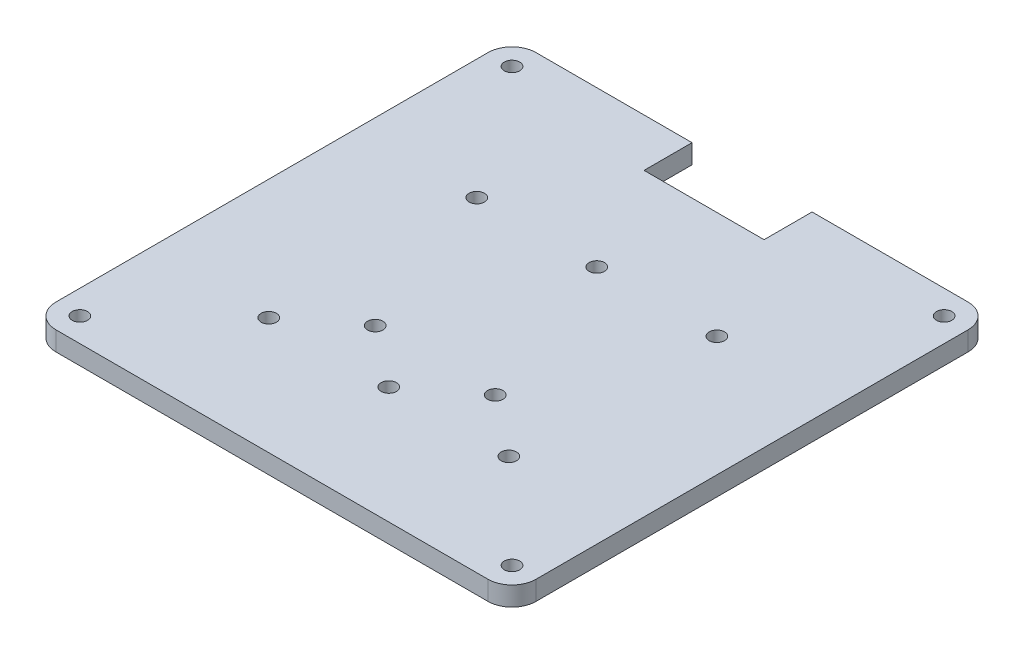
from build123d import *

# Parameters (mm, degrees)
SKETCH1_R           = 1.6
BOSS_EXTRUDE1_DEPTH = 4
FILLET1_R           = 5


with BuildPart() as part:
    # Sketch1 → Boss-Extrude1 (new body)
    with BuildSketch(Plane(origin=(0, 0, 0), x_dir=(1, 0, 0), z_dir=(0, 1, 0))):
        Polygon((-50, -50), (50, -50), (50, 50), (12.5, 50), (12.5, 40), (-12.5, 40), (-12.5, 50), (-50, 50), align=None)
        with Locations((-45, -45)):
            Circle(SKETCH1_R, mode=Mode.SUBTRACT)
        with Locations((-25, -25.66)):
            Circle(SKETCH1_R, mode=Mode.SUBTRACT)
        with Locations((-12.5, -16)):
            Circle(SKETCH1_R, mode=Mode.SUBTRACT)
        with Locations((0, -25.66)):
            Circle(SKETCH1_R, mode=Mode.SUBTRACT)
        with Locations((45, -45)):
            Circle(SKETCH1_R, mode=Mode.SUBTRACT)
        with Locations((25, -25.66)):
            Circle(SKETCH1_R, mode=Mode.SUBTRACT)
        with Locations((12.5, -16)):
            Circle(SKETCH1_R, mode=Mode.SUBTRACT)
        with Locations((-25, 17.66)):
            Circle(SKETCH1_R, mode=Mode.SUBTRACT)
        with Locations((-45, 45)):
            Circle(SKETCH1_R, mode=Mode.SUBTRACT)
        with Locations((0, 17.66)):
            Circle(SKETCH1_R, mode=Mode.SUBTRACT)
        with Locations((25, 17.66)):
            Circle(SKETCH1_R, mode=Mode.SUBTRACT)
        with Locations((45, 45)):
            Circle(SKETCH1_R, mode=Mode.SUBTRACT)
    extrude(amount=BOSS_EXTRUDE1_DEPTH)

    # Fillet1
    fillet1_edges = [part.edges().sort_by_distance(p)[0] for p in [
        (50, 2, -50),
        (50, 2, 50),
        (-50, 2, 50),
        (-50, 2, -50),
    ]]
    fillet(fillet1_edges, radius=FILLET1_R)


solid = part.part
